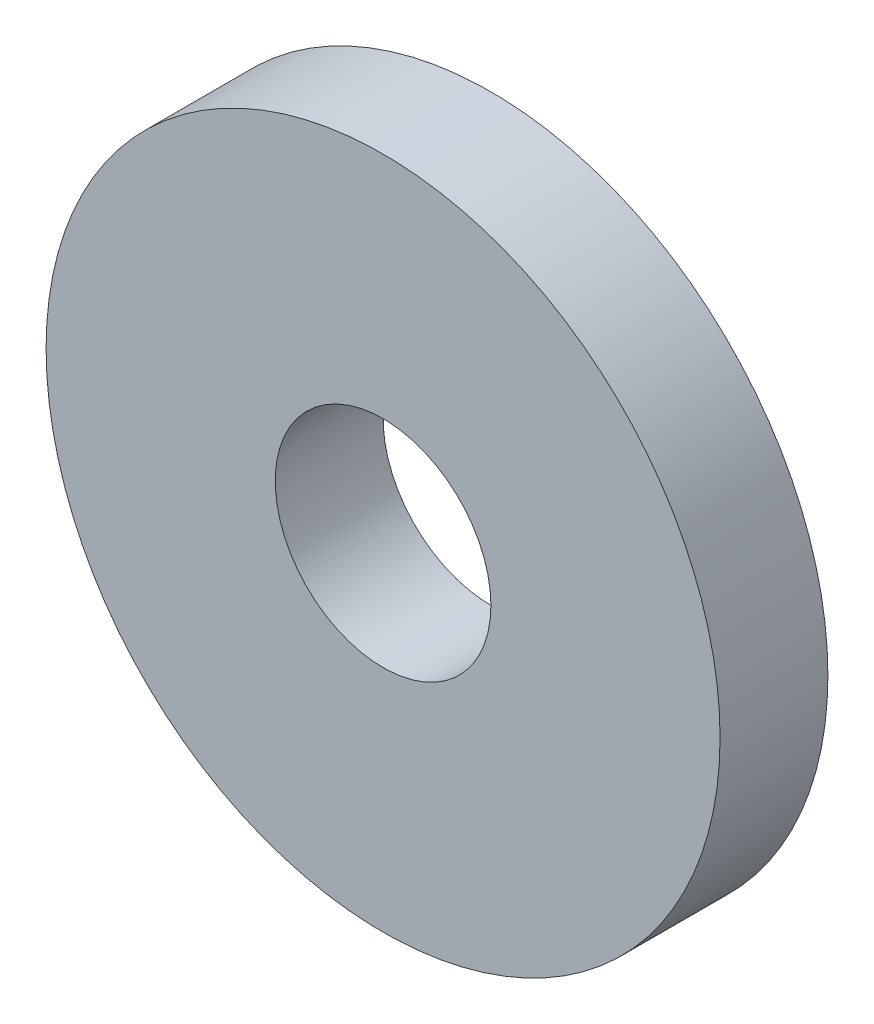
from build123d import *

# Parameters (mm, degrees)
SKETCH_1_R      = 12.5
SKETCH_1_R_2    = 4
EXTRUDE_1_DEPTH = 4


with BuildPart() as part:
    # Эскиз1 → Бобышка-Вытянуть1 (new body)
    with BuildSketch(Plane.XY):
        Circle(SKETCH_1_R)
        Circle(SKETCH_1_R_2, mode=Mode.SUBTRACT)
    extrude(amount=EXTRUDE_1_DEPTH)


solid = part.part
